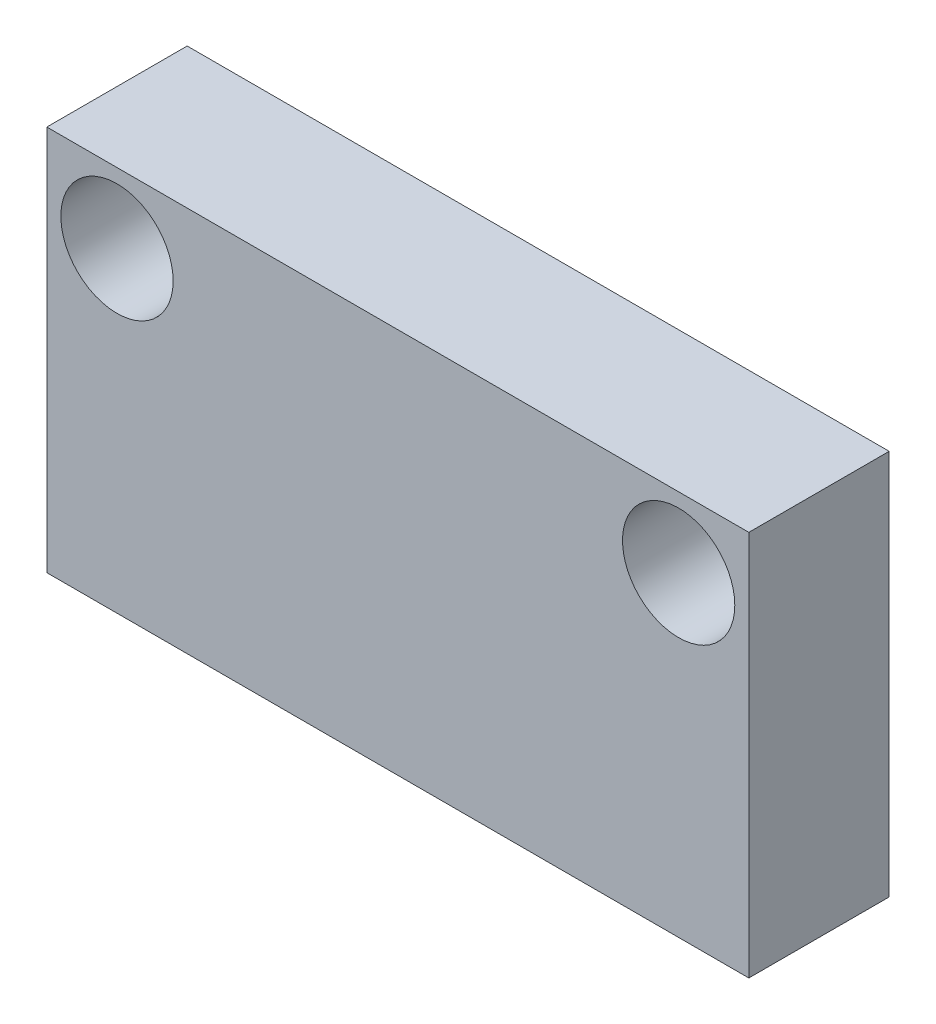
from build123d import *

# Parameters (mm, degrees)
SKETCH1_W            = 20.0076
SKETCH1_H            = 11
BOSS_EXTRUDE1_DEPTH  = 4
M3_CLEARANCE_HOLE1_D = 3.2


with BuildPart() as part:
    # Sketch1 → Boss-Extrude1 (new body)
    with BuildSketch(Plane.XY):
        with Locations((30.622339046, 2.5)):
            Rectangle(SKETCH1_W, SKETCH1_H)
    extrude(amount=BOSS_EXTRUDE1_DEPTH)

    # M3 Clearance Hole1 (through all)
    with Locations(Plane.XY.offset(4)):
        with Locations((38.626139046, 6), (22.618539046, 6)):
            Hole(M3_CLEARANCE_HOLE1_D / 2)


solid = part.part
